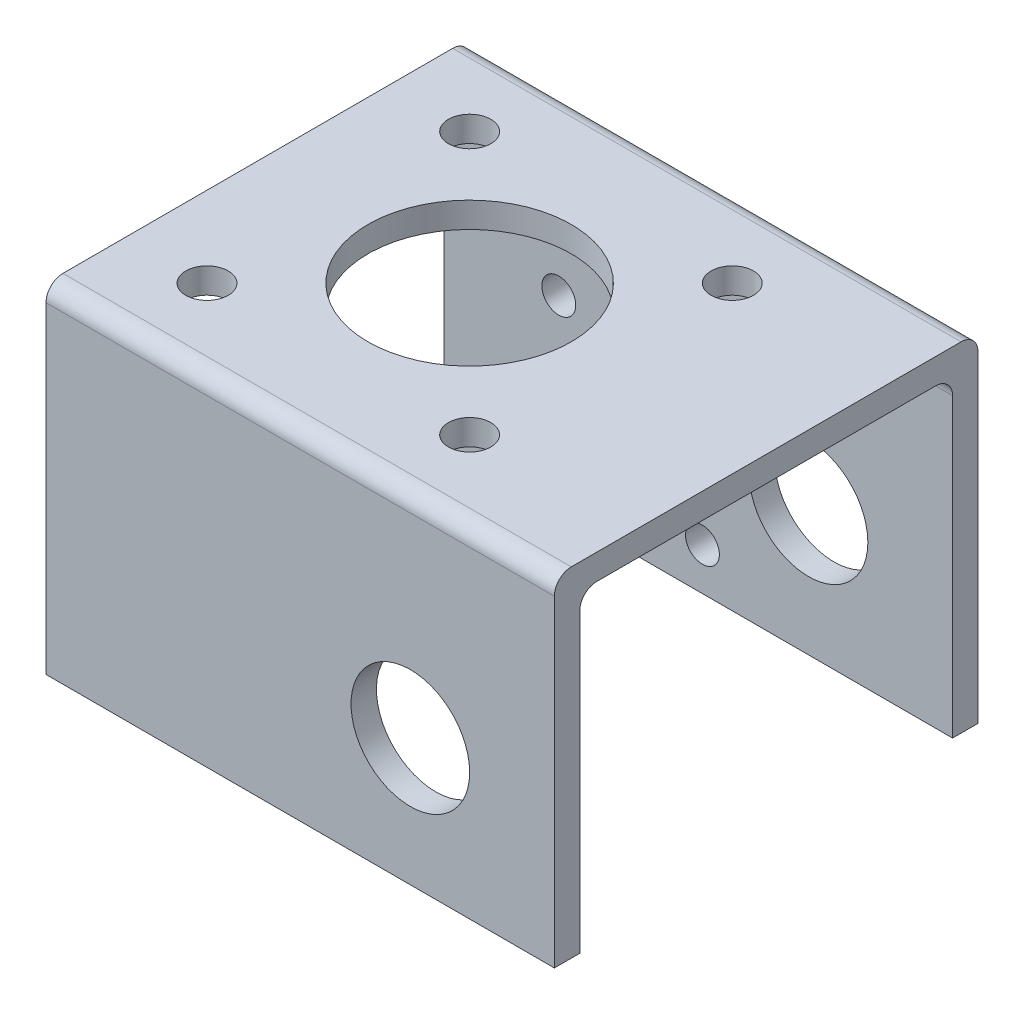
from build123d import *

# Parameters (mm, degrees)
EXTRUDE_1_DEPTH     = 60
CUT_EXTRUDE_1_REACH = 42
SKETCH_2_R          = 2.5
SKETCH_2_R_2        = 12
SKETCH_3_R          = 7
CUT_EXTRUDE_2_DEPTH = 51
CUT_EXTRUDE_3_REACH = 52
SKETCH_6_R          = 2


with BuildPart() as part:
    # 草图1 → 凸台-拉伸1 (new body)
    with BuildSketch(Plane(origin=(0, 0, 0), x_dir=(0, 0, -1), z_dir=(1, 0, 0))):
        with BuildLine():
            Line((0, 0), (3, 0))
            Line((3, 0), (3, 35))
            ThreePointArc((3, 35), (3.585786438, 36.414213562), (5, 37))
            Line((5, 37), (45, 37))
            ThreePointArc((45, 37), (46.414213562, 36.414213562), (47, 35))
            Line((47, 35), (47, 0))
            Line((47, 0), (50, 0))
            Line((50, 0), (50, 38))
            ThreePointArc((50, 38), (49.414213562, 39.414213562), (48, 40))
            Line((48, 40), (2, 40))
            ThreePointArc((2, 40), (0.585786438, 39.414213562), (0, 38))
            Line((0, 38), (0, 0))
        make_face()
    extrude(amount=EXTRUDE_1_DEPTH)

    # 草图2 → 切除-拉伸1 (cut, up to next)
    with BuildSketch(Plane(origin=(0, 40, 0), x_dir=(1, 0, 0), z_dir=(0, 1, 0)), mode=Mode.PRIVATE) as cut_extrude_1_sk1:
        with Locations((9.5, 9.5)):
            Circle(SKETCH_2_R)
    cut_extrude_1_tool1 = extrude(cut_extrude_1_sk1.sketch, amount=-CUT_EXTRUDE_1_REACH, mode=Mode.PRIVATE) & part.part
    add(cut_extrude_1_tool1.solids().sort_by_distance((9.5, 40, -9.5))[0], mode=Mode.SUBTRACT)
    # 草图2 → 切除-拉伸1 (cut, up to next)
    with BuildSketch(Plane(origin=(0, 40, 0), x_dir=(1, 0, 0), z_dir=(0, 1, 0)), mode=Mode.PRIVATE) as cut_extrude_1_sk2:
        with Locations((40.5, 9.5)):
            Circle(SKETCH_2_R)
    cut_extrude_1_tool2 = extrude(cut_extrude_1_sk2.sketch, amount=-CUT_EXTRUDE_1_REACH, mode=Mode.PRIVATE) & part.part
    add(cut_extrude_1_tool2.solids().sort_by_distance((40.5, 40, -9.5))[0], mode=Mode.SUBTRACT)
    # 草图2 → 切除-拉伸1 (cut, up to next)
    with BuildSketch(Plane(origin=(0, 40, 0), x_dir=(1, 0, 0), z_dir=(0, 1, 0)), mode=Mode.PRIVATE) as cut_extrude_1_sk3:
        with Locations((40.5, 40.5)):
            Circle(SKETCH_2_R)
    cut_extrude_1_tool3 = extrude(cut_extrude_1_sk3.sketch, amount=-CUT_EXTRUDE_1_REACH, mode=Mode.PRIVATE) & part.part
    add(cut_extrude_1_tool3.solids().sort_by_distance((40.5, 40, -40.5))[0], mode=Mode.SUBTRACT)
    # 草图2 → 切除-拉伸1 (cut, up to next)
    with BuildSketch(Plane(origin=(0, 40, 0), x_dir=(1, 0, 0), z_dir=(0, 1, 0)), mode=Mode.PRIVATE) as cut_extrude_1_sk4:
        with Locations((9.5, 40.5)):
            Circle(SKETCH_2_R)
    cut_extrude_1_tool4 = extrude(cut_extrude_1_sk4.sketch, amount=-CUT_EXTRUDE_1_REACH, mode=Mode.PRIVATE) & part.part
    add(cut_extrude_1_tool4.solids().sort_by_distance((9.5, 40, -40.5))[0], mode=Mode.SUBTRACT)
    # 草图2 → 切除-拉伸1 (cut, up to next)
    with BuildSketch(Plane(origin=(0, 40, 0), x_dir=(1, 0, 0), z_dir=(0, 1, 0)), mode=Mode.PRIVATE) as cut_extrude_1_sk5:
        with Locations((25, 25)):
            Circle(SKETCH_2_R_2)
    cut_extrude_1_tool5 = extrude(cut_extrude_1_sk5.sketch, amount=-CUT_EXTRUDE_1_REACH, mode=Mode.PRIVATE) & part.part
    add(cut_extrude_1_tool5.solids().sort_by_distance((25, 40, -25))[0], mode=Mode.SUBTRACT)

    # 草图3 → 切除-拉伸2 (cut, through all)
    with BuildSketch(Plane.XY):
        with Locations((43, 15)):
            Circle(SKETCH_3_R)
    extrude(amount=-CUT_EXTRUDE_2_DEPTH, mode=Mode.SUBTRACT)

    # 草图6 → 切除-拉伸3 (cut, up to next)
    with BuildSketch(Plane(origin=(0, 0, -50), x_dir=(-1, 0, 0), z_dir=(0, 0, -1)), mode=Mode.PRIVATE) as cut_extrude_3_sk1:
        with Locations((-13.525, 5)):
            Circle(SKETCH_6_R)
    cut_extrude_3_tool1 = extrude(cut_extrude_3_sk1.sketch, amount=-CUT_EXTRUDE_3_REACH, mode=Mode.PRIVATE) & part.part
    add(cut_extrude_3_tool1.solids().sort_by_distance((13.525, 5, -50))[0], mode=Mode.SUBTRACT)
    # 草图6 → 切除-拉伸3 (cut, up to next)
    with BuildSketch(Plane(origin=(0, 0, -50), x_dir=(-1, 0, 0), z_dir=(0, 0, -1)), mode=Mode.PRIVATE) as cut_extrude_3_sk2:
        with Locations((-30.475, 5)):
            Circle(SKETCH_6_R)
    cut_extrude_3_tool2 = extrude(cut_extrude_3_sk2.sketch, amount=-CUT_EXTRUDE_3_REACH, mode=Mode.PRIVATE) & part.part
    add(cut_extrude_3_tool2.solids().sort_by_distance((30.475, 5, -50))[0], mode=Mode.SUBTRACT)
    # 草图6 → 切除-拉伸3 (cut, up to next)
    with BuildSketch(Plane(origin=(0, 0, -50), x_dir=(-1, 0, 0), z_dir=(0, 0, -1)), mode=Mode.PRIVATE) as cut_extrude_3_sk3:
        with Locations((-30.475, 21.991100612)):
            Circle(SKETCH_6_R)
    cut_extrude_3_tool3 = extrude(cut_extrude_3_sk3.sketch, amount=-CUT_EXTRUDE_3_REACH, mode=Mode.PRIVATE) & part.part
    add(cut_extrude_3_tool3.solids().sort_by_distance((30.475, 21.991101, -50))[0], mode=Mode.SUBTRACT)
    # 草图6 → 切除-拉伸3 (cut, up to next)
    with BuildSketch(Plane(origin=(0, 0, -50), x_dir=(-1, 0, 0), z_dir=(0, 0, -1)), mode=Mode.PRIVATE) as cut_extrude_3_sk4:
        with Locations((-13.525, 21.991100612)):
            Circle(SKETCH_6_R)
    cut_extrude_3_tool4 = extrude(cut_extrude_3_sk4.sketch, amount=-CUT_EXTRUDE_3_REACH, mode=Mode.PRIVATE) & part.part
    add(cut_extrude_3_tool4.solids().sort_by_distance((13.525, 21.991101, -50))[0], mode=Mode.SUBTRACT)


solid = part.part
